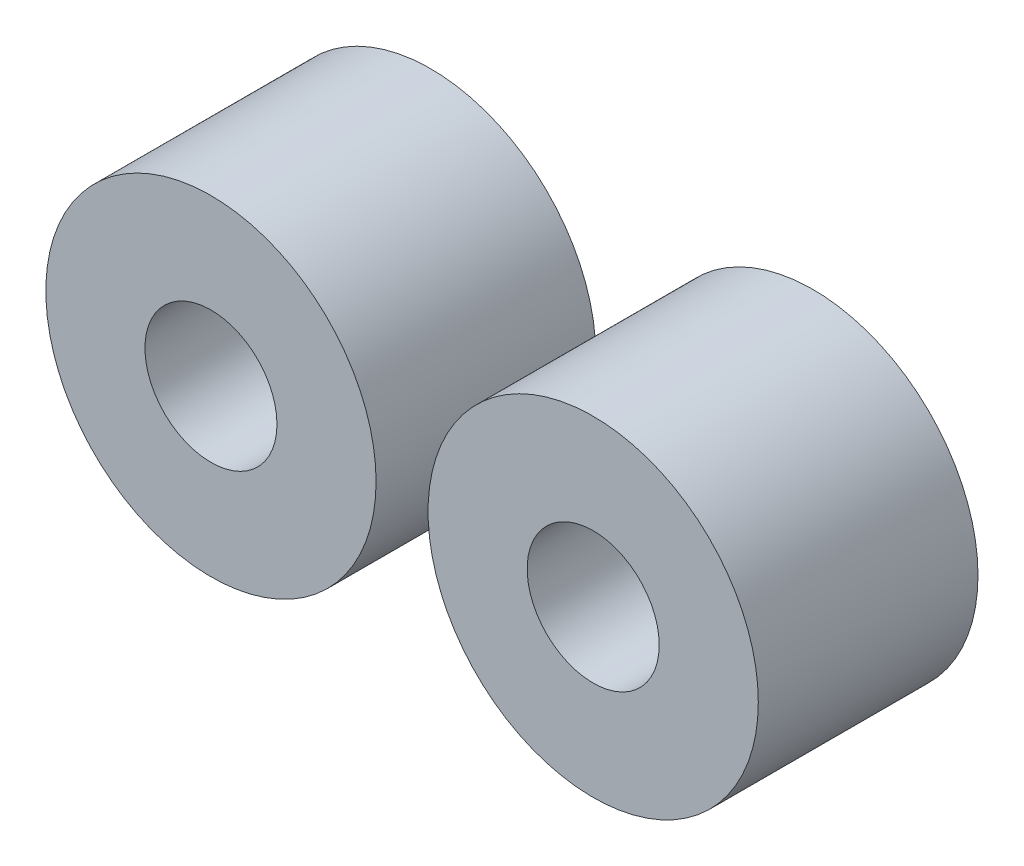
from build123d import *

# Parameters (mm, degrees)
SZKIC1_R                      = 953
SZKIC1_R_2                    = 381
DODANIE_WYCI_GNI_CIE1_DEPTH   = 1268
DODANIE_WYCI_GNI_CIE1_2_DEPTH = 1268


with BuildPart() as part:
    # Szkic1 → Dodanie-wyci_gni_cie1 (new body)
    with BuildSketch(Plane.XY):
        Circle(SZKIC1_R)
        Circle(SZKIC1_R_2, mode=Mode.SUBTRACT)
    extrude(amount=DODANIE_WYCI_GNI_CIE1_DEPTH)


with BuildPart() as body_2:
    # Szkic1 → Dodanie-wyci_gni_cie1 2 (new body)
    with BuildSketch(Plane.XY):
        with Locations((2206, 0)):
            Circle(SZKIC1_R)
        with Locations((2206, 0)):
            Circle(SZKIC1_R_2, mode=Mode.SUBTRACT)
    extrude(amount=DODANIE_WYCI_GNI_CIE1_2_DEPTH)


solid = Compound([part.part, body_2.part])
